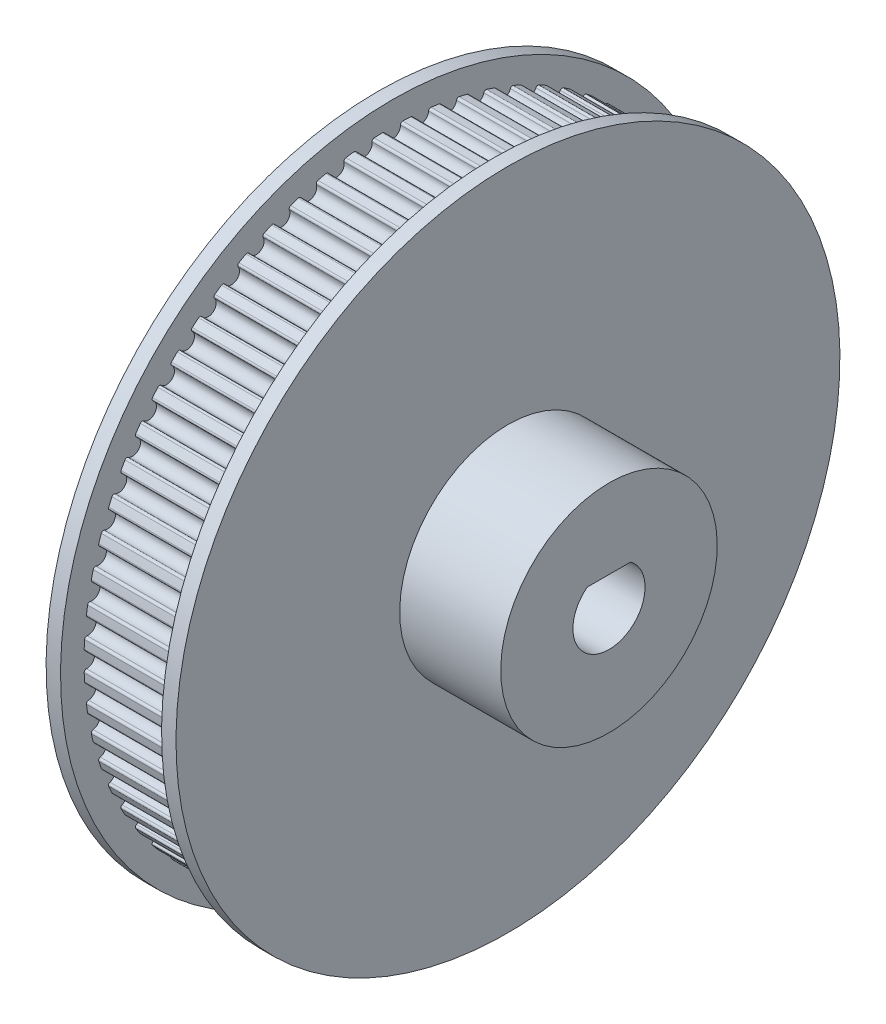
from build123d import *

# Parameters (mm, degrees)
SKETCH1_W                = 7
SKETCH1_H                = 7.5
CUT_EXTRUDE2_DEPTH       = 7
FILLET1_R                = 0.15
CIRPATTERN1_COUNT        = 68
FILLET1_OF_CIRPATTERN1_R = 0.15
CUT_EXTRUDE3_DEPTH       = 1
CUT_EXTRUDE3_DEPTH_BACK  = 17


with BuildPart() as part:
    # Sketch1 → Revolve1 (revolve)
    with BuildSketch(Plane.XY):
        Polygon((-7, 23), (-7, 0), (-16, 0), (-16, 23), (-15, 23), (-15, 21.37), (-8, 21.37), (-8, 23), align=None)
        with Locations((-3.5, 3.75)):
            Rectangle(SKETCH1_W, SKETCH1_H)
    revolve(axis=Axis((-7, 0, 0), (-1, 0, 0)))

    # Sketch3 → Cut-Extrude2 (cut)
    with BuildSketch(Plane.ZY.offset(8)):
        with BuildLine():
            ThreePointArc((0.518411276, 21.363711048), (0, 21.37), (-0.518411276, 21.363711048))
            ThreePointArc((-0.518411276, 21.363711048), (0, 20.63), (0.518411276, 21.363711048))
        make_face()
    cut_extrude2 = extrude(amount=CUT_EXTRUDE2_DEPTH, mode=Mode.SUBTRACT)

    # Fillet1
    fillet1_edges = [part.edges().sort_by_distance(p)[0] for p in [
        (-11.5, 21.363711048, -0.518411276),
        (-11.5, 21.363711048, 0.518411276),
    ]]
    fillet(fillet1_edges, radius=FILLET1_R)

    # CirPattern1: Cut-Extrude2 ×68 about axis
    cirpattern1_axis = Axis((0, 0, 0), (1, 0, 0))
    for i in range(1, CIRPATTERN1_COUNT):
        add(cut_extrude2.rotate(cirpattern1_axis, i * 360 / CIRPATTERN1_COUNT), mode=Mode.SUBTRACT)

    # Fillet1 of CirPattern1
    fillet1_of_cirpattern1_edges = [part.edges().sort_by_distance(p)[0] for p in [
        (-11.5, 21.320410181, 1.454994746),
        (-11.5, 21.224744265, 2.487394395),
        (-11.5, 21.095211092, 3.415987265),
        (-11.5, 20.904695448, 4.435155942),
        (-11.5, 20.690035099, 5.347835786),
        (-11.5, 20.40629514, 6.345078303),
        (-11.5, 20.108339022, 7.234058457),
        (-11.5, 19.733795516, 8.200866693),
        (-11.5, 19.355085687, 9.058562692),
        (-11.5, 18.892934108, 9.98668818),
        (-11.5, 18.436701585, 10.805782464),
        (-11.5, 17.890884847, 11.687306764),
        (-11.5, 17.361022046, 12.46081111),
        (-11.5, 16.736196864, 13.288213368),
        (-11.5, 16.137224388, 14.00952851),
        (-11.5, 15.438721551, 14.775749621),
        (-11.5, 14.775749621, 15.438721551),
        (-11.5, 14.00952851, 16.137224388),
        (-11.5, 13.288213368, 16.736196864),
        (-11.5, 12.46081111, 17.361022046),
        (-11.5, 11.687306764, 17.890884847),
        (-11.5, 10.805782464, 18.436701585),
        (-11.5, 9.98668818, 18.892934108),
        (-11.5, 9.058562692, 19.355085687),
        (-11.5, 8.200866693, 19.733795516),
        (-11.5, 7.234058457, 20.108339022),
        (-11.5, 6.345078303, 20.40629514),
        (-11.5, 5.347835786, 20.690035099),
        (-11.5, 4.435155942, 20.904695448),
        (-11.5, 3.415987265, 21.095211092),
        (-11.5, 2.487394395, 21.224744265),
        (-11.5, 1.454994746, 21.320410181),
        (-11.5, 0.518411276, 21.363711048),
        (-11.5, -0.518411276, 21.363711048),
        (-11.5, -1.454994746, 21.320410181),
        (-11.5, -2.487394395, 21.224744265),
        (-11.5, -3.415987265, 21.095211092),
        (-11.5, -4.435155942, 20.904695448),
        (-11.5, -5.347835786, 20.690035099),
        (-11.5, -6.345078303, 20.40629514),
        (-11.5, -7.234058457, 20.108339022),
        (-11.5, -8.200866693, 19.733795516),
        (-11.5, -9.058562692, 19.355085687),
        (-11.5, -9.98668818, 18.892934108),
        (-11.5, -10.805782464, 18.436701585),
        (-11.5, -11.687306764, 17.890884847),
        (-11.5, -12.46081111, 17.361022046),
        (-11.5, -13.288213368, 16.736196864),
        (-11.5, -14.00952851, 16.137224388),
        (-11.5, -14.775749621, 15.438721551),
        (-11.5, -15.438721551, 14.775749621),
        (-11.5, -16.137224388, 14.00952851),
        (-11.5, -16.736196864, 13.288213368),
        (-11.5, -17.361022046, 12.46081111),
        (-11.5, -17.890884847, 11.687306764),
        (-11.5, -18.436701585, 10.805782464),
        (-11.5, -18.892934108, 9.98668818),
        (-11.5, -19.355085687, 9.058562692),
        (-11.5, -19.733795516, 8.200866693),
        (-11.5, -20.108339022, 7.234058457),
        (-11.5, -20.40629514, 6.345078303),
        (-11.5, -20.690035099, 5.347835786),
        (-11.5, -20.904695448, 4.435155942),
        (-11.5, -21.095211092, 3.415987265),
        (-11.5, -21.224744265, 2.487394395),
        (-11.5, -21.320410181, 1.454994746),
        (-11.5, -21.363711048, 0.518411276),
        (-11.5, -21.363711048, -0.518411276),
        (-11.5, -21.320410181, -1.454994746),
        (-11.5, -21.224744265, -2.487394395),
        (-11.5, -21.095211092, -3.415987265),
        (-11.5, -20.904695448, -4.435155942),
        (-11.5, -20.690035099, -5.347835786),
        (-11.5, -20.40629514, -6.345078303),
        (-11.5, -20.108339022, -7.234058457),
        (-11.5, -19.733795516, -8.200866693),
        (-11.5, -19.355085687, -9.058562692),
        (-11.5, -18.892934108, -9.98668818),
        (-11.5, -18.436701585, -10.805782464),
        (-11.5, -17.890884847, -11.687306764),
        (-11.5, -17.361022046, -12.46081111),
        (-11.5, -16.736196864, -13.288213368),
        (-11.5, -16.137224388, -14.00952851),
        (-11.5, -15.438721551, -14.775749621),
        (-11.5, -14.775749621, -15.438721551),
        (-11.5, -14.00952851, -16.137224388),
        (-11.5, -13.288213368, -16.736196864),
        (-11.5, -12.46081111, -17.361022046),
        (-11.5, -11.687306764, -17.890884847),
        (-11.5, -10.805782464, -18.436701585),
        (-11.5, -9.98668818, -18.892934108),
        (-11.5, -9.058562692, -19.355085687),
        (-11.5, -8.200866693, -19.733795516),
        (-11.5, -7.234058457, -20.108339022),
        (-11.5, -6.345078303, -20.40629514),
        (-11.5, -5.347835786, -20.690035099),
        (-11.5, -4.435155942, -20.904695448),
        (-11.5, -3.415987265, -21.095211092),
        (-11.5, -2.487394395, -21.224744265),
        (-11.5, -1.454994746, -21.320410181),
        (-11.5, -0.518411276, -21.363711048),
        (-11.5, 0.518411276, -21.363711048),
        (-11.5, 1.454994746, -21.320410181),
        (-11.5, 2.487394395, -21.224744265),
        (-11.5, 3.415987265, -21.095211092),
        (-11.5, 4.435155942, -20.904695448),
        (-11.5, 5.347835786, -20.690035099),
        (-11.5, 6.345078303, -20.40629514),
        (-11.5, 7.234058457, -20.108339022),
        (-11.5, 8.200866693, -19.733795516),
        (-11.5, 9.058562692, -19.355085687),
        (-11.5, 9.98668818, -18.892934108),
        (-11.5, 10.805782464, -18.436701585),
        (-11.5, 11.687306764, -17.890884847),
        (-11.5, 12.46081111, -17.361022046),
        (-11.5, 13.288213368, -16.736196864),
        (-11.5, 14.00952851, -16.137224388),
        (-11.5, 14.775749621, -15.438721551),
        (-11.5, 15.438721551, -14.775749621),
        (-11.5, 16.137224388, -14.00952851),
        (-11.5, 16.736196864, -13.288213368),
        (-11.5, 17.361022046, -12.46081111),
        (-11.5, 17.890884847, -11.687306764),
        (-11.5, 18.436701585, -10.805782464),
        (-11.5, 18.892934108, -9.98668818),
        (-11.5, 19.355085687, -9.058562692),
        (-11.5, 19.733795516, -8.200866693),
        (-11.5, 20.108339022, -7.234058457),
        (-11.5, 20.40629514, -6.345078303),
        (-11.5, 20.690035099, -5.347835786),
        (-11.5, 20.904695448, -4.435155942),
        (-11.5, 21.095211092, -3.415987265),
        (-11.5, 21.224744265, -2.487394395),
        (-11.5, 21.320410181, -1.454994746),
    ]]
    fillet(fillet1_of_cirpattern1_edges, radius=FILLET1_OF_CIRPATTERN1_R)

    # Sketch2 → Cut-Extrude3 (cut, two sides)
    with BuildSketch(Plane.ZY.offset(16)) as cut_extrude3_sk:
        with BuildLine():
            Line((0, 2), (1.5, 2))
            ThreePointArc((1.5, 2), (0, -2.5), (-1.5, 2))
            Line((-1.5, 2), (0, 2))
        make_face()
    extrude(amount=CUT_EXTRUDE3_DEPTH, mode=Mode.SUBTRACT)
    extrude(cut_extrude3_sk.sketch, amount=-CUT_EXTRUDE3_DEPTH_BACK, mode=Mode.SUBTRACT)


solid = part.part
